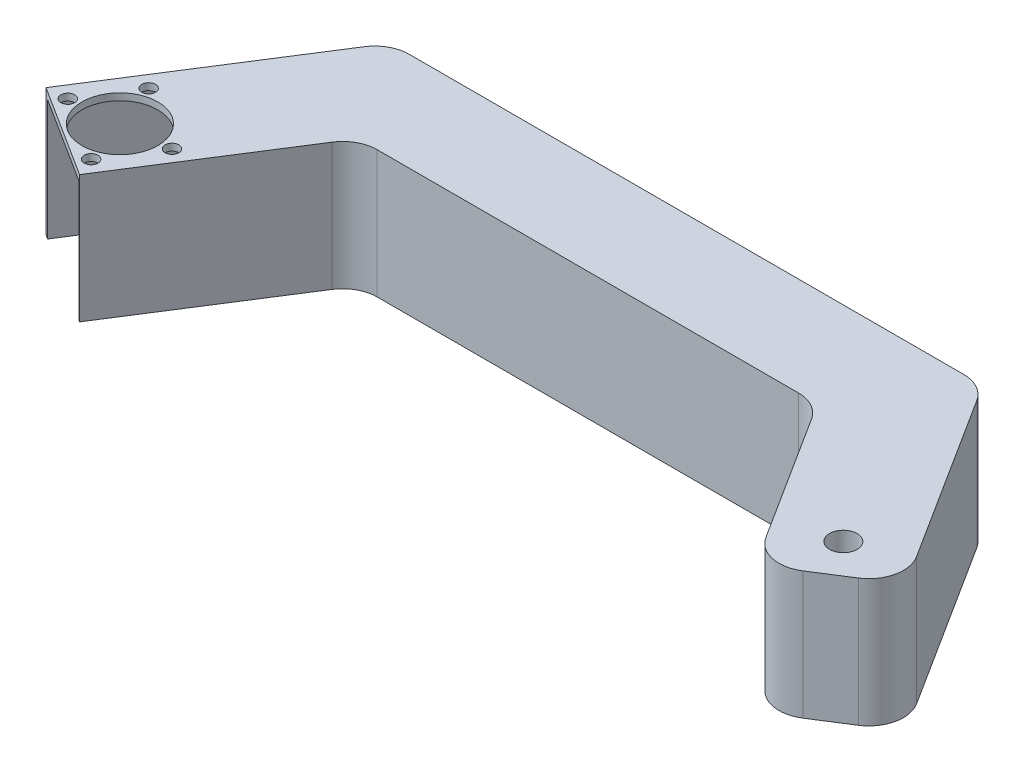
from build123d import *

# Parameters (mm, degrees)
BOSS_EXTRUDE1_DEPTH = 37
SKETCH3_R           = 11
SKETCH3_R_2         = 2
SKETCH3_R_3         = 4
CUT_EXTRUDE1_DEPTH  = 92
CUT_EXTRUDE5_DEPTH  = 35


with BuildPart() as part:
    # Sketch1 → Boss-Extrude1 (new body)
    with BuildSketch(Plane(origin=(0, 0, 0), x_dir=(1, 0, 0), z_dir=(0, 1, 0))):
        with BuildLine():
            Line((30.91362152, -11.506988518), (61.410209359, 36.471719739))
            ThreePointArc((61.410209359, 36.471719739), (65.035248289, 39.872184028), (69.84963689, 41.10738726))
            Line((69.84963689, 41.10738726), (230.684249594, 41.10738726))
            ThreePointArc((230.684249594, 41.10738726), (235.498638195, 39.872184028), (239.123677125, 36.471719739))
            Line((239.123677125, 36.471719739), (269.620264964, -11.506988518))
            ThreePointArc((269.620264964, -11.506988518), (270.941569742, -19.045741561), (266.545169913, -25.310748528))
            Line((266.545169913, -25.310748528), (256.707586966, -31.563787081))
            ThreePointArc((256.707586966, -31.563787081), (249.168833923, -32.885091859), (242.903826956, -28.488692029))
            Line((242.903826956, -28.488692029), (219.802518103, 7.855405338))
            ThreePointArc((219.802518103, 7.855405338), (216.177479173, 11.255869627), (211.363090572, 12.491072858))
            Line((211.363090572, 12.491072858), (89.170795912, 12.491072858))
            ThreePointArc((89.170795912, 12.491072858), (84.356407311, 11.255869627), (80.731368381, 7.855405338))
            Line((80.731368381, 7.855405338), (57.630059528, -28.488692029))
            Line((57.630059528, -28.488692029), (52.265727049, -36.92811956))
            Line((52.265727049, -36.92811956), (25.54928904, -19.946416049))
            Line((25.54928904, -19.946416049), (30.91362152, -11.506988518))
        make_face()
    extrude(amount=BOSS_EXTRUDE1_DEPTH)

    # Sketch3 → Cut-Extrude1 (cut)
    with BuildSketch(Plane(origin=(0, 37, 0), x_dir=(1, 0, 0), z_dir=(0, 1, 0))):
        with Locations((45.34470702, -18.309954767)):
            Circle(SKETCH3_R)
        with Locations((40.621019343, -5.235675639)):
            Circle(SKETCH3_R_2)
        with Locations((59.187759911, -17.037207093)):
            Circle(SKETCH3_R_2)
        with Locations((255.189179464, -18.309954767)):
            Circle(SKETCH3_R_3)
        with Locations((50.068394696, -31.384233896)):
            Circle(SKETCH3_R_2)
        with Locations((31.501654128, -19.582702442)):
            Circle(SKETCH3_R_2)
    extrude(amount=-CUT_EXTRUDE1_DEPTH, mode=Mode.SUBTRACT)

    # Sketch9 → Cut-Extrude5 (cut)
    with BuildSketch(Plane.XZ):
        Polygon((26.248657405, 21.639699706), (55.167500935, -23.851457954), (78.921967938, -9.666420768), (51.214594578, 37.510608863), align=None)
    extrude(amount=-CUT_EXTRUDE5_DEPTH, mode=Mode.SUBTRACT)


solid = part.part
